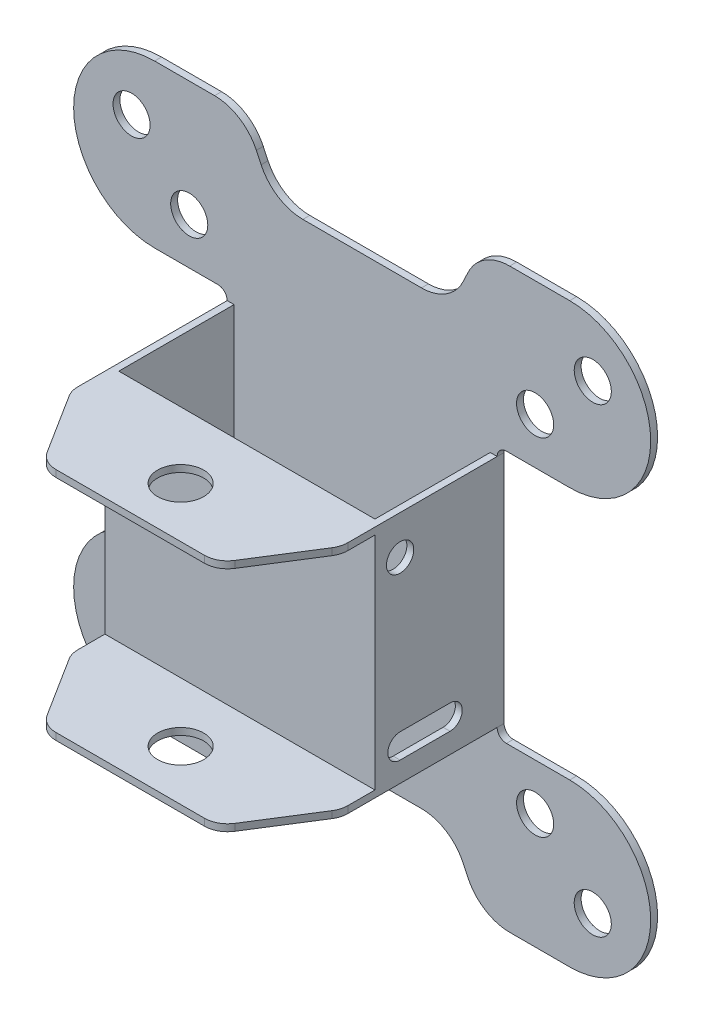
from build123d import *

# Parameters (mm, degrees)
SKETCH1_R           = 4.022928706
BOSS_EXTRUDE1_DEPTH = 1.5
SKETCH3_W           = 1.5
SKETCH3_H           = 50.876500294
BOSS_EXTRUDE2_DEPTH = 25
SKETCH4_W           = 58.54657641
SKETCH4_H           = 50.876500294
BOSS_EXTRUDE3_DEPTH = 1.5
SKETCH5_R           = 5
BOSS_EXTRUDE4_DEPTH = 1.5
SKETCH8_R           = 2.960999365
CUT_EXTRUDE1_DEPTH  = 92.835038059
FILLET1_R           = 5


with BuildPart() as part:
    # Sketch1 → Boss-Extrude1 (new body)
    with BuildSketch(Plane.XY):
        with BuildLine():
            Line((-31.273288205, 27.438250147), (-45, 27.438250147))
            ThreePointArc((-45, 27.438250147), (-62.561749853, 45), (-45, 62.561749853))
            Line((-45, 62.561749853), (-31.990503674, 62.561749853))
            ThreePointArc((-31.990503674, 62.561749853), (-26.633250489, 61.005673012), (-22.943256827, 56.821717516))
            Line((-22.943256827, 56.821717516), (-21.912531254, 54.632680079))
            ThreePointArc((-21.912531254, 54.632680079), (-18.222537592, 50.448724583), (-12.865284407, 48.892647742))
            Line((-12.865284407, 48.892647742), (12.865284407, 48.892647742))
            ThreePointArc((12.865284407, 48.892647742), (18.222537592, 50.448724583), (21.912531254, 54.632680079))
            Line((21.912531254, 54.632680079), (22.943256827, 56.821717516))
            ThreePointArc((22.943256827, 56.821717516), (26.633250489, 61.005673012), (31.990503674, 62.561749853))
            Line((31.990503674, 62.561749853), (45, 62.561749853))
            ThreePointArc((45, 62.561749853), (62.561749853, 45), (45, 27.438250147))
            Line((45, 27.438250147), (31.273288205, 27.438250147))
            ThreePointArc((31.273288205, 27.438250147), (29.859074643, 26.852463709), (29.273288205, 25.438250147))
            Line((29.273288205, 25.438250147), (29.273288205, -25.438250147))
            ThreePointArc((29.273288205, -25.438250147), (29.859074643, -26.852463709), (31.273288205, -27.438250147))
            Line((31.273288205, -27.438250147), (45, -27.438250147))
            ThreePointArc((45, -27.438250147), (62.561749853, -45), (45, -62.561749853))
            Line((45, -62.561749853), (31.990503674, -62.561749853))
            ThreePointArc((31.990503674, -62.561749853), (26.633250489, -61.005673012), (22.943256827, -56.821717516))
            Line((22.943256827, -56.821717516), (21.912531254, -54.632680079))
            ThreePointArc((21.912531254, -54.632680079), (18.222537592, -50.448724583), (12.865284407, -48.892647742))
            Line((12.865284407, -48.892647742), (-12.865284407, -48.892647742))
            ThreePointArc((-12.865284407, -48.892647742), (-18.222537592, -50.448724583), (-21.912531254, -54.632680079))
            Line((-21.912531254, -54.632680079), (-22.943256827, -56.821717516))
            ThreePointArc((-22.943256827, -56.821717516), (-26.633250489, -61.005673012), (-31.990503674, -62.561749853))
            Line((-31.990503674, -62.561749853), (-45, -62.561749853))
            ThreePointArc((-45, -62.561749853), (-62.561749853, -45), (-45, -27.438250147))
            Line((-45, -27.438250147), (-31.273288205, -27.438250147))
            ThreePointArc((-31.273288205, -27.438250147), (-29.859074643, -26.852463709), (-29.273288205, -25.438250147))
            Line((-29.273288205, -25.438250147), (-29.273288205, 25.438250147))
            ThreePointArc((-29.273288205, 25.438250147), (-29.859074643, 26.852463709), (-31.273288205, 27.438250147))
        make_face()
        with Locations((-50, 50)):
            Circle(SKETCH1_R, mode=Mode.SUBTRACT)
        with Locations((50, 50)):
            Circle(SKETCH1_R, mode=Mode.SUBTRACT)
        with Locations((-37.5, 37.5)):
            Circle(SKETCH1_R, mode=Mode.SUBTRACT)
        with Locations((37.5, 37.5)):
            Circle(SKETCH1_R, mode=Mode.SUBTRACT)
        with Locations((50, -50)):
            Circle(SKETCH1_R, mode=Mode.SUBTRACT)
        with Locations((37.5, -37.5)):
            Circle(SKETCH1_R, mode=Mode.SUBTRACT)
        with Locations((-37.5, -37.5)):
            Circle(SKETCH1_R, mode=Mode.SUBTRACT)
        with Locations((-50, -50)):
            Circle(SKETCH1_R, mode=Mode.SUBTRACT)
    extrude(amount=BOSS_EXTRUDE1_DEPTH)

    # Sketch3 → Boss-Extrude2 (add)
    with BuildSketch(Plane.XY.offset(1.5)):
        with Locations((-28.523288205, 0)):
            Rectangle(SKETCH3_W, SKETCH3_H)
        with Locations((28.523288205, 0)):
            Rectangle(SKETCH3_W, SKETCH3_H)
    extrude(amount=BOSS_EXTRUDE2_DEPTH)

    # Sketch4 → Boss-Extrude3 (add)
    with BuildSketch(Plane.XY.offset(26.5)):
        Rectangle(SKETCH4_W, SKETCH4_H)
    extrude(amount=BOSS_EXTRUDE3_DEPTH)

    # Sketch5 → Boss-Extrude4 (add)
    with BuildSketch(Plane(origin=(0, 25.438250147, 0), x_dir=(1, 0, 0), z_dir=(0, 1, 0))):
        Polygon((-29.273288205, -28), (-29.273288205, -35.308019153), (-18.871561113, -51.78577911), (18.871561113, -51.78577911), (29.273288205, -35.308019153), (29.273288205, -28), align=None)
        with Locations((0, -40.861297371)):
            Circle(SKETCH5_R, mode=Mode.SUBTRACT)
    boss_extrude4 = extrude(amount=-BOSS_EXTRUDE4_DEPTH)

    # Mirror1: Boss-Extrude4 across plane
    add(boss_extrude4.mirror(Plane.ZX))

    # Sketch8 → Cut-Extrude1 (cut, through all)
    with BuildSketch(Plane.ZY.offset(29.273288205)):
        with Locations((22.546846222, 17.00872447)):
            Circle(SKETCH8_R)
        with BuildLine():
            Line((11.727810079, -15.733095436), (22.546846222, -15.733095436))
            ThreePointArc((22.546846222, -15.733095436), (25.204153345, -18.390402559), (22.546846222, -21.047709682))
            Line((22.546846222, -21.047709682), (11.727810079, -21.047709682))
            ThreePointArc((11.727810079, -21.047709682), (9.070502956, -18.390402559), (11.727810079, -15.733095436))
        make_face()
    extrude(amount=-CUT_EXTRUDE1_DEPTH, mode=Mode.SUBTRACT)

    # Fillet1
    fillet1_edges = [part.edges().sort_by_distance(p)[0] for p in [
        (29.273288205, 24.688250147, 35.308019153),
        (18.871561113, 24.688250147, 51.78577911),
        (-18.871561113, 24.688250147, 51.78577911),
        (-29.273288205, 24.688250147, 35.308019153),
        (-29.273288205, -24.688250147, 35.308019153),
        (-18.871561113, -24.688250147, 51.78577911),
        (18.871561113, -24.688250147, 51.78577911),
        (29.273288205, -24.688250147, 35.308019153),
    ]]
    fillet(fillet1_edges, radius=FILLET1_R)


solid = part.part
